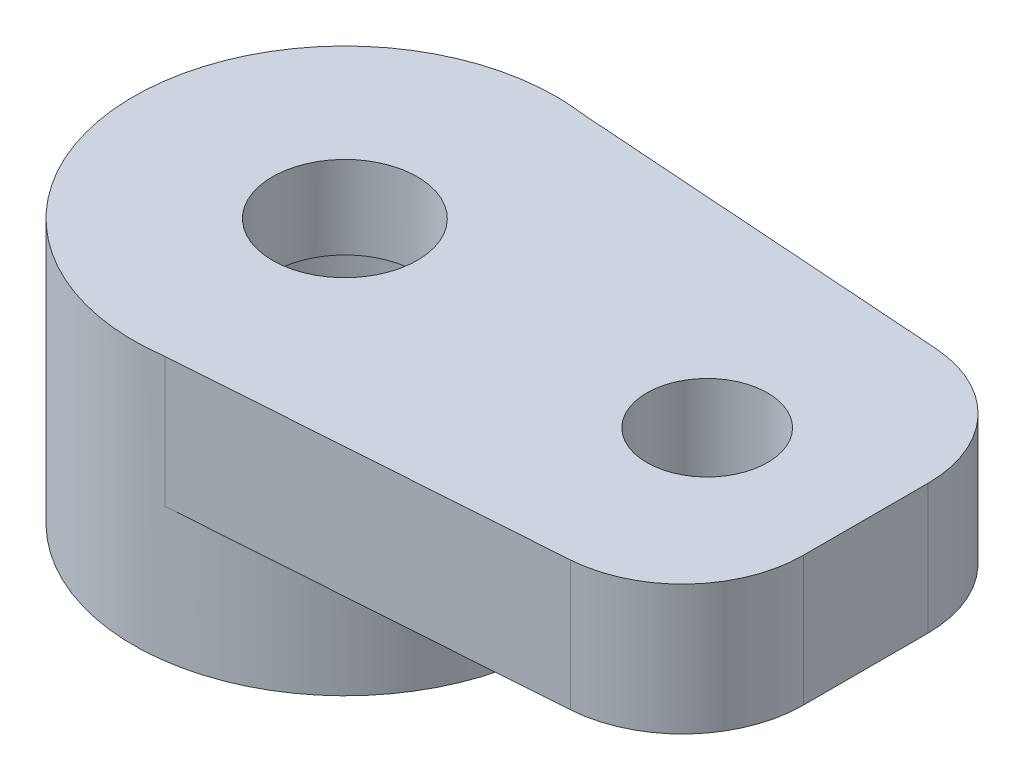
from build123d import *

# Parameters (mm, degrees)
SALIENTE_EXTRUIR1_DEPTH = 2.15
CROQUIS2_R              = 3.5
SALIENTE_EXTRUIR2_DEPTH = 2.22
CROQUIS3_R              = 1.2
CORTAR_EXTRUIR1_DEPTH   = 7.22
CROQUIS4_R              = 2.175
CORTAR_EXTRUIR2_DEPTH   = 3
CROQUIS5_R              = 1
CORTAR_EXTRUIR3_DEPTH   = 10
CUT_EXTRUDE1_DEPTH      = 10
FILLET1_R               = 2


with BuildPart() as part:
    # Croquis1 → Saliente-Extruir1 (new body)
    with BuildSketch(Plane(origin=(0, 0, 0), x_dir=(1, 0, 0), z_dir=(0, 1, 0))):
        with BuildLine():
            Line((0.486006459, 3.466092573), (21.5, 2))
            ThreePointArc((21.5, 2), (23.5, 0), (21.5, -2))
            Line((21.5, -2), (0.486006459, -3.466092573))
            ThreePointArc((0.486006459, -3.466092573), (-3.5, 0), (0.486006459, 3.466092573))
        make_face()
    extrude(amount=SALIENTE_EXTRUIR1_DEPTH)

    # Croquis2 → Saliente-Extruir2 (add)
    with BuildSketch(Plane.XZ):
        Circle(CROQUIS2_R)
    extrude(amount=SALIENTE_EXTRUIR2_DEPTH)

    # Croquis3 → Cortar-Extruir1 (cut)
    with BuildSketch(Plane(origin=(0, 2.15, 0), x_dir=(1, 0, 0), z_dir=(0, 1, 0))):
        Circle(CROQUIS3_R)
    extrude(amount=-CORTAR_EXTRUIR1_DEPTH, mode=Mode.SUBTRACT)

    # Croquis4 → Cortar-Extruir2 (cut)
    with BuildSketch(Plane.XZ.offset(2.22)):
        Circle(CROQUIS4_R)
    extrude(amount=-CORTAR_EXTRUIR2_DEPTH, mode=Mode.SUBTRACT)

    # Croquis5 → Cortar-Extruir3 (cut)
    with BuildSketch(Plane(origin=(0, 2.15, 0), x_dir=(1, 0, 0), z_dir=(0, 1, 0))):
        with Locations((21.5, 0)):
            Circle(CROQUIS5_R)
        with Locations((15.5, 0)):
            Circle(CROQUIS5_R)
        with Locations((6, 0)):
            Circle(CROQUIS5_R)
    extrude(amount=-CORTAR_EXTRUIR3_DEPTH, mode=Mode.SUBTRACT)

    # Sketch1 → Cut-Extrude1 (cut)
    with BuildSketch(Plane(origin=(0, 2.15, 0), x_dir=(1, 0, 0), z_dir=(0, 1, 0))):
        with BuildLine():
            Line((21.5, 2), (8.624907291, 2.898262282))
            Line((8.624907291, 2.898262282), (8.624907291, -2.898262282))
            Line((8.624907291, -2.898262282), (21.5, -2))
            ThreePointArc((21.5, -2), (23.5, 0), (21.5, 2))
        make_face()
    extrude(amount=-CUT_EXTRUDE1_DEPTH, mode=Mode.SUBTRACT)

    # Fillet1
    fillet1_edges = [part.edges().sort_by_distance(p)[0] for p in [
        (8.624907291, 1.075, 2.898262282),
        (8.624907291, 1.075, -2.898262282),
    ]]
    fillet(fillet1_edges, radius=FILLET1_R)


solid = part.part
